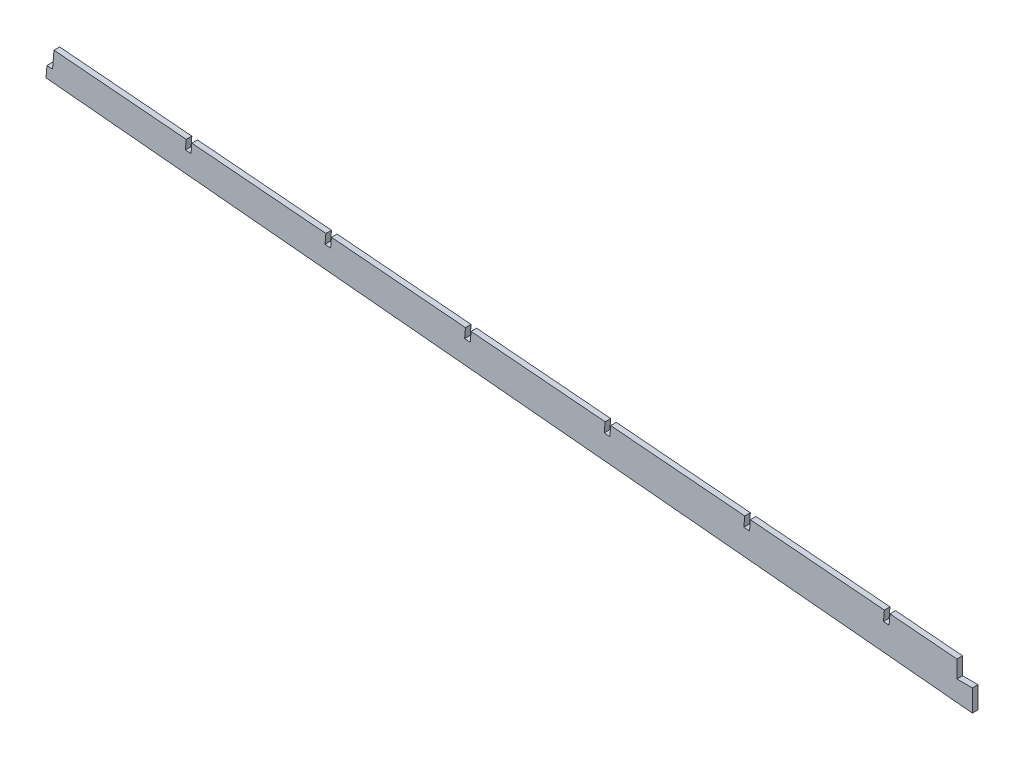
from build123d import *

# Parameters (mm, degrees)
BOSS_EXTRUDE1_DEPTH = 3.175
CUT_EXTRUDE1_DEPTH  = 4.175
CUT_EXTRUDE2_DEPTH  = 7.62


with BuildPart() as part:
    # Sketch1 → Boss-Extrude1 (new body)
    with BuildSketch(Plane.XY):
        Polygon((-950.530495659, 69.619322302), (-951.061849964, 63.291592645), (-11.536706102, -24.902638492), (-8.372841274, -25.168315645), (0, -25.545856054), (152.4, -25.545856054), (152.4, -7.765856054), (139.7, -7.765856054), (139.7, -12.845856054), (136.525, -12.845856054), (136.525, -7.765856054), (95.25, -7.765856054), (95.25, -12.845856054), (92.075, -12.845856054), (92.075, -7.765856054), (79.375, -7.765856054), (79.375, -12.845856054), (76.2, -12.845856054), (76.2, -7.765856054), (69.85, -7.765856054), (25.4, -0.145856054), (19.05, -0.145856054), (19.05, -5.225856054), (15.875, -5.225856054), (15.875, -0.145856054), (3.175, -0.145856054), (3.175, -6.495856054), (0, -6.495856054), (0, -0.145856054), (-2.81225704, -0.145856054), (-6.247424053, 0.14260298), (-6.778778359, -6.185126677), (-9.942643187, -5.919449524), (-9.411288881, 0.408280132), (-946.54805097, 79.101852726), (-947.366630831, 69.353645149), align=None)
    extrude(amount=BOSS_EXTRUDE1_DEPTH)

    # Sketch2 → Cut-Extrude1 (cut, through all)
    with BuildSketch(Plane.XY.offset(3.175)):
        Polygon((-869.047169109, 67.116306724), (-868.590421605, 72.555567687), (-871.754286433, 72.821244839), (-872.210759203, 67.385255598), align=None)
        Polygon((-790.083960364, 60.403342827), (-789.620355495, 65.924265958), (-792.784220323, 66.189943111), (-793.247550458, 60.672291701), align=None)
        Polygon((-711.120751618, 53.69037893), (-710.650289385, 59.29296423), (-713.814154213, 59.558641383), (-714.284341712, 53.959327804), align=None)
        Polygon((-632.157542872, 46.977415032), (-631.680223276, 52.661662502), (-634.844088104, 52.927339654), (-635.321132966, 47.246363906), align=None)
        Polygon((-553.194334126, 40.264451135), (-552.710157166, 46.030360773), (-555.874021994, 46.296037926), (-556.35792422, 40.533400009), align=None)
        Polygon((-474.23112538, 33.551487238), (-473.740091056, 39.399059045), (-476.903955884, 39.664736197), (-477.394715474, 33.820436112), align=None)
        Polygon((-395.267916634, 26.83852334), (-394.770024946, 32.767757316), (-397.933889774, 33.033434469), (-398.431506728, 27.107472214), align=None)
        Polygon((-316.304707888, 20.125559443), (-315.799958836, 26.136455588), (-318.963823664, 26.402132741), (-319.468297982, 20.394508317), align=None)
        Polygon((-237.341499142, 13.412595546), (-236.829892727, 19.50515386), (-239.993757555, 19.770831012), (-240.505089236, 13.68154442), align=None)
        Polygon((-158.378290396, 6.699631648), (-157.859826617, 12.873852131), (-161.023691445, 13.139529284), (-161.54188049, 6.968580522), align=None)
        Polygon((-79.415081651, -0.013332249), (-78.889760507, 6.242550403), (-82.053625335, 6.508227555), (-82.578671745, 0.255616625), align=None)
    extrude(amount=-CUT_EXTRUDE1_DEPTH, mode=Mode.SUBTRACT)

    # Sketch3 → Cut-Extrude2 (cut)
    with BuildSketch(Plane.XY.offset(3.175)):
        Polygon((-435.836990415, 36.216246757), (-435.836990415, 26.451619727), (-427.115588921, 26.451619727), (-427.115588921, 14.108196169), (150.838987184, -84.054223576), (191.196568658, 26.451619727), align=None)
    extrude(amount=-CUT_EXTRUDE2_DEPTH, mode=Mode.SUBTRACT)


solid = part.part
